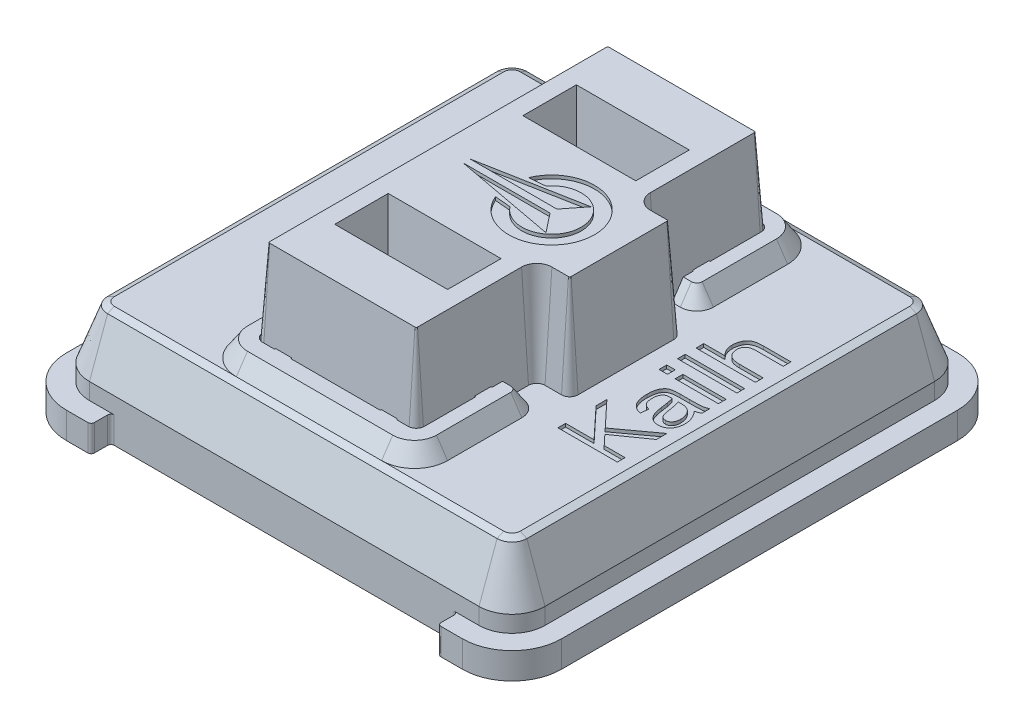
from build123d import *
from OCP.BRepFilletAPI import BRepFilletAPI_MakeChamfer

# Parameters (mm, degrees)
BOSS_EXTRUDE4_DEPTH     = 0.4
BOSS_EXTRUDE5_DEPTH     = 0.5
BOSS_EXTRUDE6_DEPTH     = 1.6
BOSS_EXTRUDE6_TAPER     = 20.000000000000043
CHAMFER1_SIZE           = 0.1
CHAMFER1_SIZE2          = 0.16731571851014881
BOSS_EXTRUDE7_DEPTH     = 0.5
BOSS_EXTRUDE7_TAPER     = 34.000000000000064
CUT_EXTRUDE1_DEPTH      = 11.995908329919814
BOSS_EXTRUDE8_DEPTH     = 0.5
BOSS_EXTRUDE9_DEPTH     = 3
BOSS_EXTRUDE9_DRAFT     = 4.000000000000004
SKETCH13_W              = 1.799999999999999
SKETCH13_H              = 0.23376623376623384
SKETCH13_W_2            = 1.3090909090909086
SKETCH13_H_2            = 0.23376623376623368
SKETCH13_W_3            = 0.25714285714285623
CUT_EXTRUDE2_DEPTH      = 0.1
CUT_EXTRUDE3_DEPTH      = 0.1
BOSS_EXTRUDE10_START    = 1.3
BOSS_EXTRUDE10_DEPTH    = 1.3
BOSS_EXTRUDE11_DEPTH    = 0.9000000000000002
BOSS_EXTRUDE11_TAPER    = 25.000000000000018
CUT_EXTRUDE4_DEPTH      = 4
SKETCH19_R              = 1.6
SKETCH19_R_2            = 0.8999999999999999
BOSS_EXTRUDE12_DEPTH    = 2.65
CHAMFER2_SIZE           = 0.5
SKETCH20_W              = 0.34999999999999964
SKETCH20_H              = 1.15
SKETCH20_W_2            = 0.5
SKETCH20_H_2            = 0.8499999999999996
BOSS_EXTRUDE13_DEPTH    = 3
CUT_EXTRUDE5_REACH      = 18.489
BOSS_EXTRUDE14_START    = 2
BOSS_EXTRUDE14_DEPTH    = 3
MIRROR2_START           = 2
MIRROR2_COPY_1_DEPTH    = 3
CUT_EXTRUDE6_REACH      = 14.137
SKETCH23_W              = 10.5
SKETCH23_H              = 0.599999999999997
FILLET1_R               = 0.1
ESQUISSE1_W             = 16.584048611465096
ESQUISSE1_H             = 15.552754131229735
ENL_V_MAT_EXTRU_1_DEPTH = 10


with BuildPart() as part:
    # Sketch5 → Boss-Extrude4 (new, symmetric)
    with BuildSketch(Plane(origin=(0, 0, 0), x_dir=(1, 0, 0), z_dir=(0, 1, 0))):
        with BuildLine():
            Line((5.999999999999988, -7.4999999999999964), (-5.999999999999988, -7.4999999999999964))
            ThreePointArc((-5.999999999999988, -7.4999999999999964), (-7.06066017177982, -7.060660171779818), (-7.499999999999999, -5.999999999999986))
            Line((-7.499999999999999, -5.999999999999986), (-7.499999999999999, 5.999999999999986))
            ThreePointArc((-7.499999999999999, 5.999999999999986), (-7.06066017177982, 7.060660171779818), (-5.999999999999988, 7.4999999999999964))
            Line((-5.999999999999988, 7.4999999999999964), (5.999999999999988, 7.4999999999999964))
            ThreePointArc((5.999999999999988, 7.4999999999999964), (7.06066017177982, 7.060660171779817), (7.499999999999999, 5.999999999999986))
            Line((7.499999999999999, 5.999999999999986), (7.499999999999999, -5.999999999999986))
            ThreePointArc((7.499999999999999, -5.999999999999986), (7.06066017177982, -7.060660171779817), (5.999999999999988, -7.4999999999999964))
        make_face()
    extrude(amount=BOSS_EXTRUDE4_DEPTH, both=True)

    # Sketch6 → Boss-Extrude5 (add)
    with BuildSketch(Plane(origin=(0, 0.4, 0), x_dir=(1, 0, 0), z_dir=(0, 1, 0))):
        with BuildLine():
            Line((5.899999999999993, -6.900000000000001), (-5.899999999999995, -6.900000000000001))
            ThreePointArc((-5.899999999999995, -6.900000000000001), (-6.607106781186548, -6.607106781186549), (-6.900000000000001, -5.899999999999995))
            Line((-6.900000000000001, -5.899999999999995), (-6.900000000000001, 5.899999999999992))
            ThreePointArc((-6.900000000000001, 5.899999999999992), (-6.607106781186548, 6.6071067811865465), (-5.899999999999995, 6.899999999999999))
            Line((-5.899999999999995, 6.899999999999999), (5.899999999999992, 6.899999999999999))
            ThreePointArc((5.899999999999992, 6.899999999999999), (6.6071067811865465, 6.6071067811865465), (6.899999999999999, 5.899999999999992))
            Line((6.899999999999999, 5.899999999999992), (6.8999999999999995, -5.899999999999995))
            ThreePointArc((6.8999999999999995, -5.899999999999995), (6.607106781186547, -6.607106781186548), (5.899999999999993, -6.900000000000001))
        make_face()
    extrude(amount=BOSS_EXTRUDE5_DEPTH)

    # Sketch7 → Boss-Extrude6 (add)
    with BuildSketch(Plane(origin=(0, 0.9, 0), x_dir=(1, 0, 0), z_dir=(0, 1, 0))):
        with BuildLine():
            Line((-6.900000000000001, 5.899999999999992), (-6.900000000000001, -5.899999999999995))
            ThreePointArc((-6.900000000000001, -5.899999999999995), (-6.607106781186549, -6.607106781186548), (-5.899999999999995, -6.900000000000001))
            Line((-5.899999999999995, -6.900000000000001), (5.899999999999993, -6.900000000000001))
            ThreePointArc((5.899999999999993, -6.900000000000001), (6.607106781186547, -6.607106781186548), (6.8999999999999995, -5.899999999999995))
            Line((6.8999999999999995, -5.899999999999995), (6.899999999999999, 5.899999999999992))
            ThreePointArc((6.899999999999999, 5.899999999999992), (6.6071067811865465, 6.6071067811865465), (5.899999999999992, 6.899999999999999))
            Line((5.899999999999992, 6.899999999999999), (-5.899999999999995, 6.899999999999999))
            ThreePointArc((-5.899999999999995, 6.899999999999999), (-6.607106781186548, 6.6071067811865465), (-6.900000000000001, 5.899999999999992))
        make_face()
    extrude(amount=BOSS_EXTRUDE6_DEPTH, taper=BOSS_EXTRUDE6_TAPER)

    # Chamfer1: one chamfer whose edges measure the first distance from different faces: ONE call of the kernel's chamfer builder (chamfer() names one face for all edges)
    chamfer1_edges_1 = [part.edges().sort_by_distance(p)[0] for p in [
        (-6.195321467907047, 2.5, -6.1953214679070445),
    ]]
    chamfer1_side_1 = [part.faces().sort_by_distance(p)[0] for p in [
        (-6.401214124546798, 1.7000000000000002, -6.4012141245467955),
    ]]
    chamfer1_edges_2 = [part.edges().sort_by_distance(p)[0] for p in [
        (-6.317647625174076, 2.5, 1.38e-15),
    ]]
    chamfer1_side_2 = [part.faces().sort_by_distance(p)[0] for p in [
        (-6.608823812587039, 1.7, 1.04e-15),
    ]]
    chamfer1_edges_3 = [part.edges().sort_by_distance(p)[0] for p in [
        (-6.195321467907047, 2.5, 6.195321467907046),
    ]]
    chamfer1_side_3 = [part.faces().sort_by_distance(p)[0] for p in [
        (-6.401214124546797, 1.7000000000000002, 6.401214124546797),
    ]]
    chamfer1_edges_4 = [part.edges().sort_by_distance(p)[0] for p in [
        (-1.3e-15, 2.5, 6.317647625174076),
    ]]
    chamfer1_side_4 = [part.faces().sort_by_distance(p)[0] for p in [
        (-8.5e-16, 1.7, 6.608823812587039),
    ]]
    chamfer1_edges_5 = [part.edges().sort_by_distance(p)[0] for p in [
        (6.1953214679070445, 2.5, 6.195321467907047),
    ]]
    chamfer1_side_5 = [part.faces().sort_by_distance(p)[0] for p in [
        (6.4012141245467955, 1.7000000000000002, 6.401214124546797),
    ]]
    chamfer1_edges_6 = [part.edges().sort_by_distance(p)[0] for p in [
        (6.317647625174073, 2.5, -3.9e-16),
    ]]
    chamfer1_side_6 = [part.faces().sort_by_distance(p)[0] for p in [
        (6.608823812587037, 1.7000000000000002, 7e-16),
    ]]
    chamfer1_edges_7 = [part.edges().sort_by_distance(p)[0] for p in [
        (6.195321467907045, 2.5, -6.1953214679070445),
    ]]
    chamfer1_side_7 = [part.faces().sort_by_distance(p)[0] for p in [
        (6.4012141245467955, 1.7000000000000002, -6.4012141245467955),
    ]]
    chamfer1_edges_8 = [part.edges().sort_by_distance(p)[0] for p in [
        (-4.1e-16, 2.5, -6.317647625174073),
    ]]
    chamfer1_side_8 = [part.faces().sort_by_distance(p)[0] for p in [
        (-8.5e-16, 1.7, -6.608823812587036),
    ]]
    chamfer1 = BRepFilletAPI_MakeChamfer(part.part.solid().wrapped)
    for e in chamfer1_edges_1:
        chamfer1.Add(CHAMFER1_SIZE, CHAMFER1_SIZE2, e.wrapped, chamfer1_side_1[0].wrapped)  # the first distance lies on this face
    for e in chamfer1_edges_2:
        chamfer1.Add(CHAMFER1_SIZE, CHAMFER1_SIZE2, e.wrapped, chamfer1_side_2[0].wrapped)  # the first distance lies on this face
    for e in chamfer1_edges_3:
        chamfer1.Add(CHAMFER1_SIZE, CHAMFER1_SIZE2, e.wrapped, chamfer1_side_3[0].wrapped)  # the first distance lies on this face
    for e in chamfer1_edges_4:
        chamfer1.Add(CHAMFER1_SIZE, CHAMFER1_SIZE2, e.wrapped, chamfer1_side_4[0].wrapped)  # the first distance lies on this face
    for e in chamfer1_edges_5:
        chamfer1.Add(CHAMFER1_SIZE, CHAMFER1_SIZE2, e.wrapped, chamfer1_side_5[0].wrapped)  # the first distance lies on this face
    for e in chamfer1_edges_6:
        chamfer1.Add(CHAMFER1_SIZE, CHAMFER1_SIZE2, e.wrapped, chamfer1_side_6[0].wrapped)  # the first distance lies on this face
    for e in chamfer1_edges_7:
        chamfer1.Add(CHAMFER1_SIZE, CHAMFER1_SIZE2, e.wrapped, chamfer1_side_7[0].wrapped)  # the first distance lies on this face
    for e in chamfer1_edges_8:
        chamfer1.Add(CHAMFER1_SIZE, CHAMFER1_SIZE2, e.wrapped, chamfer1_side_8[0].wrapped)  # the first distance lies on this face
    add(Compound.cast(chamfer1.Shape()), mode=Mode.REPLACE)

    # Sketch8 → Boss-Extrude7 (add)
    with BuildSketch(Plane(origin=(0, 2.5, 0), x_dir=(1, 0, 0), z_dir=(0, 1, 0))):
        with BuildLine():
            ThreePointArc((2.1999999999999926, -6.150331906663926), (2.907106781186547, -5.857438687850474), (3.1999999999999997, -5.150331906663919))
            Line((3.1999999999999997, -5.150331906663919), (3.1999999999999997, -2.9003319066639257))
            ThreePointArc((3.1999999999999997, -2.9003319066639257), (3.0535533905932737, -2.5467785160706518), (2.6999999999999997, -2.4003319066639257))
            Line((2.6999999999999997, -2.4003319066639257), (2.3000000000000003, -2.4003319066639257))
            Line((2.3000000000000003, -2.4003319066639257), (2.3, 2.4003319066639257))
            Line((2.3, 2.4003319066639257), (2.699999999999996, 2.4003319066639257))
            ThreePointArc((2.699999999999996, 2.4003319066639257), (3.0535533905932737, 2.5467785160706518), (3.1999999999999997, 2.9003319066639293))
            Line((3.1999999999999997, 2.9003319066639293), (3.1999999999999997, 5.150331906663919))
            ThreePointArc((3.1999999999999997, 5.150331906663919), (2.907106781186547, 5.857438687850474), (2.1999999999999926, 6.150331906663926))
            Line((2.1999999999999926, 6.150331906663926), (-2.1999999999999935, 6.150331906663926))
            ThreePointArc((-2.1999999999999935, 6.150331906663926), (-2.907106781186548, 5.857438687850474), (-3.2000000000000006, 5.150331906663919))
            Line((-3.2000000000000006, 5.150331906663919), (-3.2000000000000006, -5.150331906663919))
            ThreePointArc((-3.2000000000000006, -5.150331906663919), (-2.907106781186548, -5.857438687850474), (-2.1999999999999935, -6.150331906663926))
            Line((-2.1999999999999935, -6.150331906663926), (2.1999999999999926, -6.150331906663926))
        make_face()
    extrude(amount=BOSS_EXTRUDE7_DEPTH, taper=BOSS_EXTRUDE7_TAPER)

    # Sketch9 → Cut-Extrude1 (cut, through all)
    with BuildSketch(Plane(origin=(0, 2.5, 0), x_dir=(1, 0, 0), z_dir=(0, 1, 0))):
        with BuildLine():
            Line((-2.1999999999999997, -5.35), (2.2, -5.35))
            ThreePointArc((2.2, -5.35), (2.376776695296637, -5.276776695296636), (2.4500000000000006, -5.1))
            Line((2.4500000000000006, -5.1), (2.4500000000000006, 5.1))
            ThreePointArc((2.4500000000000006, 5.1), (2.376776695296637, 5.276776695296636), (2.2, 5.35))
            Line((2.2, 5.35), (-2.1999999999999997, 5.35))
            ThreePointArc((-2.1999999999999997, 5.35), (-2.3767766952966367, 5.276776695296636), (-2.4499999999999997, 5.1))
            Line((-2.4499999999999997, 5.1), (-2.4499999999999997, -5.1))
            ThreePointArc((-2.4499999999999997, -5.1), (-2.3767766952966367, -5.276776695296636), (-2.1999999999999997, -5.35))
        make_face()
    extrude(amount=CUT_EXTRUDE1_DEPTH, mode=Mode.SUBTRACT)

    # Sketch11 → Boss-Extrude8 (add)
    with BuildSketch(Plane(origin=(0, 2.5, 0), x_dir=(1, 0, 0), z_dir=(0, 1, 0))):
        with BuildLine():
            Line((-1.8598076211353325, 5.35), (-1.3401923788646686, 5.3500000000000005))
            ThreePointArc((-1.3401923788646686, 5.3500000000000005), (-1.6000000000000003, 5.199999999999999), (-1.8598076211353325, 5.35))
        make_face()
        with BuildLine():
            Line((1.3401923788646686, 5.3500000000000005), (1.8598076211353325, 5.35))
            ThreePointArc((1.8598076211353325, 5.35), (1.6000000000000003, 5.199999999999999), (1.3401923788646686, 5.3500000000000005))
        make_face()
        with BuildLine():
            Line((2.4500000000000006, 3.5598076211353322), (2.4500000000000006, 3.040192378864668))
            ThreePointArc((2.4500000000000006, 3.040192378864668), (2.2999999999999994, 3.3), (2.4500000000000006, 3.5598076211353322))
        make_face()
        with BuildLine():
            Line((2.4500000000000006, -3.0401923788646683), (2.4500000000000006, -3.5598076211353313))
            ThreePointArc((2.4500000000000006, -3.5598076211353313), (2.3000000000000007, -3.3), (2.4500000000000006, -3.0401923788646683))
        make_face()
        with BuildLine():
            Line((1.859807621135331, -5.35), (1.3401923788646677, -5.35))
            ThreePointArc((1.3401923788646677, -5.35), (1.6, -5.199999999999998), (1.859807621135331, -5.35))
        make_face()
        with BuildLine():
            Line((-1.3401923788646677, -5.35), (-1.859807621135331, -5.35))
            ThreePointArc((-1.859807621135331, -5.35), (-1.5999999999999992, -5.199999999999999), (-1.3401923788646677, -5.35))
        make_face()
        with BuildLine():
            Line((-2.4499999999999997, -3.5598076211353313), (-2.4499999999999993, -3.0401923788646683))
            ThreePointArc((-2.4499999999999993, -3.0401923788646683), (-2.2999999999999994, -3.3000000000000003), (-2.4499999999999997, -3.5598076211353313))
        make_face()
        with BuildLine():
            Line((-2.449999999999999, 3.0401923788646683), (-2.449999999999999, 3.5598076211353313))
            ThreePointArc((-2.449999999999999, 3.5598076211353313), (-2.299999999999999, 3.3), (-2.449999999999999, 3.0401923788646683))
        make_face()
    extrude(amount=BOSS_EXTRUDE8_DEPTH)


with BuildPart() as boss_extrude9_tool:
    # Sketch12 → Boss-Extrude9 (with draft: the straight prism first)
    with BuildSketch(Plane(origin=(0, 2.5, 0), x_dir=(1, 0, 0), z_dir=(0, 1, 0))):
        with BuildLine():
            ThreePointArc((2.6999999999999993, 1.6999999999999997), (2.5232233047033628, 1.7732233047033628), (2.4499999999999993, 1.9499999999999995))
            Line((2.4499999999999993, 1.9499999999999995), (2.4499999999999997, 5.099999999999998))
            ThreePointArc((2.4499999999999997, 5.099999999999998), (2.3767766952966367, 5.276776695296637), (2.199999999999998, 5.35))
            Line((2.199999999999998, 5.35), (-2.199999999999998, 5.35))
            ThreePointArc((-2.199999999999998, 5.35), (-2.3767766952966367, 5.276776695296637), (-2.4499999999999997, 5.099999999999998))
            Line((-2.4499999999999997, 5.099999999999998), (-2.4499999999999997, -5.099999999999998))
            ThreePointArc((-2.4499999999999997, -5.099999999999998), (-2.3767766952966367, -5.276776695296637), (-2.199999999999998, -5.35))
            Line((-2.199999999999998, -5.35), (2.199999999999998, -5.35))
            ThreePointArc((2.199999999999998, -5.35), (2.3767766952966367, -5.276776695296636), (2.4499999999999997, -5.099999999999998))
            Line((2.4499999999999997, -5.099999999999998), (2.449999999999999, -1.9500000000000004))
            ThreePointArc((2.449999999999999, -1.9500000000000004), (2.5232233047033623, -1.7732233047033634), (2.6999999999999993, -1.7000000000000004))
            Line((2.6999999999999993, -1.7000000000000004), (3.1999999999999975, -1.7000000000000006))
            ThreePointArc((3.1999999999999975, -1.7000000000000006), (3.3767766952966363, -1.6267766952966372), (3.4499999999999993, -1.4499999999999986))
            Line((3.4499999999999993, -1.4499999999999986), (3.4499999999999993, 1.449999999999998))
            ThreePointArc((3.4499999999999993, 1.449999999999998), (3.3767766952966363, 1.6267766952966367), (3.1999999999999975, 1.6999999999999997))
            Line((3.1999999999999975, 1.6999999999999997), (2.6999999999999993, 1.6999999999999997))
        make_face()
        Polygon((-1.5000000000000004, -2.2500000000000013), (1.4999999999999996, -2.2500000000000013), (1.5, -3.4500000000000006), (-1.5, -3.4500000000000006), align=None, mode=Mode.SUBTRACT)
        Polygon((1.4999999999999996, 2.2500000000000013), (1.5, 3.4500000000000006), (-1.5, 3.4500000000000006), (-1.5000000000000004, 2.2500000000000013), align=None, mode=Mode.SUBTRACT)
    extrude(amount=BOSS_EXTRUDE9_DEPTH)
    # Boss-Extrude9: the draft: its side faces are tilted about the plane it starts from
    boss_extrude9_sides = [boss_extrude9_tool.faces().sort_by_distance(p)[0] for p in [
        (2.95, 4, -1.7),
        (2.523223305, 4, -1.773223305),
        (2.45, 4, -3.525),
        (2.376776695, 4, -5.276776695),
        (0, 4, -5.35),
        (-2.376776695, 4, -5.276776695),
        (-2.45, 4, 0),
        (-2.376776695, 4, 5.276776695),
        (0, 4, 5.35),
        (2.376776695, 4, 5.276776695),
        (2.45, 4, 3.525),
        (2.523223305, 4, 1.773223305),
        (2.95, 4, 1.7),
        (3.376776695, 4, 1.626776695),
        (3.45, 4, 0),
        (3.376776695, 4, -1.626776695),
        (0, 4, 2.25),
        (1.5, 4, 2.85),
        (0, 4, 3.45),
        (-1.5, 4, 2.85),
        (0, 4, -2.25),
        (-1.5, 4, -2.85),
        (0, 4, -3.45),
        (1.5, 4, -2.85),
    ]]
    draft(boss_extrude9_sides, Plane(origin=(0, 2.5, 0), x_dir=(1, 0, 0), z_dir=(0, 1, 0)), BOSS_EXTRUDE9_DRAFT)


with BuildPart() as part_1:
    add(part.part)

    # Boss-Extrude9: add boss_extrude9_tool
    add(boss_extrude9_tool.part)

    # Sketch13 → Cut-Extrude2 (cut)
    # profile 1 of 6: a face of its own
    with BuildSketch(Plane(origin=(0, 2.5, 0), x_dir=(1, 0, 0), z_dir=(0, 1, 0))):
        with BuildLine():
            Line((5.808966831260708, 2.641558441558442), (5.808966831260708, 2.407792207792208))
            Line((5.808966831260708, 2.407792207792208), (4.983845078013955, 2.407792207792208))
            add(Edge.make_bspline(
                [(4.983845078013955, 2.407792207792208), (4.970936937987347, 2.407542406260028), (4.945817291259644, 2.4070562846168273), (4.909388829537622, 2.404446327773024), (4.875533983787305, 2.3986845529071656), (4.844041788617271, 2.3916782041743367), (4.815157057405047, 2.3820295974230006), (4.788467982544043, 2.370938235014907), (4.76477812513214, 2.356842463642668), (4.74322837391324, 2.3411870649661166), (4.724636948675216, 2.322986558780508), (4.707844497346048, 2.3033641068930986), (4.694403121572682, 2.2809814749147597), (4.682944049961972, 2.256818630216123), (4.6742465252240155, 2.230417316179967), (4.668184159240792, 2.2019983442445166), (4.66389616835546, 2.1717202021884994), (4.6636423768311674, 2.150786980540251), (4.6635122858061635, 2.1400568181818187)],
                knots=[0, 0, 0, 0, 1.2972783551700766, 2.5245445061948706, 3.6648949627077094, 4.745058113257756, 5.762506365238955, 6.7214970436470525, 7.642596806820658, 8.525874585350033, 9.39109206720355, 10.251017649372987, 11.113376332231878, 12.005421350727158, 12.933884526935351, 13.898554589722258, 14.922819868887679, 16, 16, 16, 16], degree=3))
            add(Edge.make_bspline(
                [(4.6635122858061635, 2.1400568181818187), (4.663785205943969, 2.1292047975292503), (4.664327167446585, 2.107654986414011), (4.66891947185136, 2.0757509701628627), (4.6760240121807595, 2.0445829921752665), (4.686851369518582, 2.014620956025939), (4.700167829324783, 1.9854327210485339), (4.716078390118673, 1.9568415750558832), (4.73570868933388, 1.9296426160727786), (4.7575320886071655, 1.9029132005118794), (4.783330672401592, 1.8782273309201394), (4.814429220574406, 1.8572274976130505), (4.849948580547092, 1.8394512413448831), (4.89005592438308, 1.8249217409321132), (4.934595652434697, 1.8136176473029308), (4.983754863262196, 1.8059125229971111), (5.037541460961735, 1.800531571486795), (5.075023484650014, 1.800181881897381), (5.094518779312656, 1.8000000000000005)],
                knots=[0, 0, 0, 0, 0.8362054097120233, 1.6605265700973175, 2.4801317730402395, 3.2965059310675793, 4.1113678837462215, 4.951934169313966, 5.813922886019306, 6.693615501295894, 7.6099018852787, 8.554965245663075, 9.57498769822485, 10.664785272825679, 11.83718286940016, 13.111757415166943, 14.497756131931636, 16, 16, 16, 16], degree=3))
            Line((5.094518779312656, 1.8000000000000005), (5.808966831260708, 1.8000000000000005))
            Line((5.808966831260708, 1.8000000000000005), (5.808966831260708, 1.5662337662337664))
            Line((5.808966831260708, 1.5662337662337664), (4.008966831260709, 1.5662337662337664))
            Line((4.008966831260709, 1.5662337662337664), (4.008966831260709, 1.8000000000000005))
            Line((4.008966831260709, 1.8000000000000005), (4.654746052039929, 1.8000000000000005))
            add(Edge.make_bspline(
                [(4.654746052039929, 1.8000000000000005), (4.640587268225019, 1.8132416381214425), (4.612790149898402, 1.8392381775496645), (4.576436737364106, 1.8823687896270296), (4.545512997028346, 1.9278700105851003), (4.520153010498332, 1.9758505241977433), (4.500661093710448, 2.026392369279579), (4.486816633622833, 2.079314401328632), (4.478177777445173, 2.1347826772544454), (4.477065304085907, 2.1726549891213955), (4.476499298793176, 2.1919237012987014)],
                knots=[0, 0, 0, 0, 1.0459544956214468, 2.0534617421327868, 3.0380182977429215, 4.011318372678219, 4.9769517403428445, 5.955962446214011, 6.9600325577727205, 8, 8, 8, 8], degree=3))
            add(Edge.make_bspline(
                [(4.476499298793176, 2.1919237012987014), (4.477151582793741, 2.21277888482019), (4.478447675797427, 2.254218284574451), (4.488265102185742, 2.3157097148811725), (4.504316498091638, 2.3757223907282032), (4.523072482923445, 2.424142919941128), (4.5413475287910305, 2.460944025525365), (4.556678390313753, 2.486720067646266), (4.573903343982798, 2.510222970711106), (4.592950461451007, 2.5314273616548295), (4.613634983780957, 2.550582276277968), (4.635796332997107, 2.567919296762635), (4.660269486175782, 2.582453577853053), (4.686358421444562, 2.595400662956551), (4.714781427402648, 2.6063064439066825), (4.745540233069591, 2.6157833065900173), (4.778855645113474, 2.623760719216385), (4.814825745795724, 2.630327347062428), (4.853357065642652, 2.6353283002399457), (4.894542377636706, 2.6389704691017455), (4.938285293293962, 2.641164747420887), (4.968379824838619, 2.64142480221953), (4.983845078013955, 2.641558441558442)],
                knots=[0, 0, 0, 0, 1.5968089331520274, 3.172870842583649, 4.756281426330583, 6.34771723513016, 7.140081275106954, 7.901324872717275, 8.641779931057476, 9.368185131844692, 10.08081263976222, 10.798910289841917, 11.5185804625579, 12.256741901371203, 13.027352034049343, 13.847329809568349, 14.720365742585669, 15.649518335311587, 16.64656909042814, 17.695141442598235, 18.815558199646286, 20, 20, 20, 20], degree=3))
            Line((4.983845078013955, 2.641558441558442), (5.808966831260708, 2.641558441558442))
        make_face()
    # profile 2 of 6: a face of its own
    with BuildSketch(Plane(origin=(0, 2.5, 0), x_dir=(1, 0, 0), z_dir=(0, 1, 0))):
        with Locations((4.908966831260709, 1.1220779220779225)):
            Rectangle(SKETCH13_W, SKETCH13_H)
    # profile 3 of 6: a face of its own
    with BuildSketch(Plane(origin=(0, 2.5, 0), x_dir=(1, 0, 0), z_dir=(0, 1, 0))):
        with Locations((5.154421376715254, 0.5610389610389616)):
            Rectangle(SKETCH13_W_2, SKETCH13_H_2)
    # profile 4 of 6: a face of its own
    with BuildSketch(Plane(origin=(0, 2.5, 0), x_dir=(1, 0, 0), z_dir=(0, 1, 0))):
        with Locations((4.137538259832137, 0.5610389610389616)):
            Rectangle(SKETCH13_W_3, SKETCH13_H_2)
    # profile 5 of 6: a face of its own
    with BuildSketch(Plane(origin=(0, 2.5, 0), x_dir=(1, 0, 0), z_dir=(0, 1, 0))):
        with BuildLine():
            Line((5.808966831260708, 0.18701298701298769), (5.808966831260708, -0.04675324675324595))
            add(Edge.make_bspline(
                [(5.808966831260708, -0.04675324675324595), (5.7976142124163745, -0.05478679368631185), (5.7743238351672606, -0.07126795466644732), (5.733813191132734, -0.08980997433740275), (5.689119615174492, -0.10624044539384754), (5.656887568182907, -0.11325507851090857), (5.640216831260709, -0.11688311688311617)],
                knots=[0, 0, 0, 0, 0.903907977573099, 1.8544054094329567, 2.8902770286238817, 4, 4, 4, 4], degree=3))
            add(Edge.make_bspline(
                [(5.640216831260709, -0.11688311688311617), (5.655516269991555, -0.13501758155964783), (5.685611532777377, -0.17068957512239877), (5.724423214156069, -0.22753996575106764), (5.758209315632795, -0.2850162411995688), (5.785193746113217, -0.3439309765148028), (5.806296030921507, -0.40396525614362766), (5.821118572850905, -0.4650232117771859), (5.830806032465317, -0.5272477785338032), (5.83182865628761, -0.5691604908149904), (5.832343454637331, -0.5902597402597396)],
                knots=[0, 0, 0, 0, 1.0892239949737048, 2.142593786481002, 3.1574900276556006, 4.148481358184637, 5.114232063249363, 6.075958248606488, 7.031419475255834, 8, 8, 8, 8], degree=3))
            add(Edge.make_bspline(
                [(5.832343454637331, -0.5902597402597396), (5.832153360297348, -0.6068352336235396), (5.831783364459901, -0.6390974437912494), (5.826299867785243, -0.6860584678131948), (5.818566199820707, -0.7303404833298883), (5.807164390100491, -0.7719074962510519), (5.792565368740574, -0.8108311868327565), (5.774591503740437, -0.8471820687217165), (5.753427790168004, -0.8809496085632283), (5.728914091941531, -0.9115819072067921), (5.701926449075696, -0.9389415065317661), (5.672743481759093, -0.9630412796162902), (5.641437274499284, -0.9835012763922452), (5.607803212122262, -1.0000777379656591), (5.572247331081473, -1.012844349874836), (5.534551659180995, -1.0220298965542784), (5.49476474669227, -1.027559476424988), (5.46746671619991, -1.0282300400753384), (5.453569103987981, -1.028571428571428)],
                knots=[0, 0, 0, 0, 1.2168275773517123, 2.368408962361388, 3.4683010163723482, 4.516243969315997, 5.529495403481963, 6.5174065446954765, 7.490059769080957, 8.451006561644878, 9.39329404916929, 10.30823430893489, 11.226054902901527, 12.133974608059562, 13.056228933753905, 13.995455658021518, 14.979472898814782, 16, 16, 16, 16], degree=3))
            add(Edge.make_bspline(
                [(5.453569103987981, -1.028571428571428), (5.440276716431007, -1.0282386520238744), (5.414063323195936, -1.0275823965195083), (5.375806254773276, -1.021871116649069), (5.3390927196081, -1.0132772402654373), (5.304512495067037, -1.0003745013096057), (5.271566778477137, -0.9841331764233306), (5.240409017381131, -0.9643582816606489), (5.211090288328932, -0.9407738117304028), (5.1833836727754115, -0.9136089664633258), (5.15795231534794, -0.8817760352618369), (5.13488061401357, -0.844866649676713), (5.114139733934651, -0.8025902440879535), (5.095679414069346, -0.754997155547491), (5.079325113390285, -0.7022504346619654), (5.065164097593691, -0.6443006182713761), (5.053127451273279, -0.5811412956759465), (5.047187307794613, -0.5370866020377416), (5.044112935156812, -0.5142857142857136)],
                knots=[0, 0, 0, 0, 0.8723930238073564, 1.7204118741329395, 2.5348632349864415, 3.3443153788029036, 4.138098067301036, 4.94323479147576, 5.762342769512937, 6.604727131961653, 7.486268004825613, 8.431224693875162, 9.457417050898199, 10.573914373813508, 11.780129899965775, 13.081285495030452, 14.489394061968598, 16, 16, 16, 16], degree=3))
            Line((5.044112935156812, -0.5142857142857136), (5.013065857234734, -0.3075487012987006))
            add(Edge.make_bspline(
                [(5.013065857234734, -0.3075487012987006), (5.009896710319499, -0.2890201951662468), (5.003852868143418, -0.2536847027393368), (4.993323302570418, -0.2032936700516332), (4.98157734400181, -0.15810403775962822), (4.971952893840244, -0.13010418045169944), (4.967408389702267, -0.11688311688311617)],
                knots=[0, 0, 0, 0, 1.1488224325496723, 2.190905520122856, 3.145775892462998, 4, 4, 4, 4], degree=3))
            add(Edge.make_bspline(
                [(4.967408389702267, -0.11688311688311617), (4.95304107021996, -0.11694396018433391), (4.926493015823697, -0.11705638695067444), (4.890070365263306, -0.11806677840113408), (4.8604658690387765, -0.11983126638462667), (4.8364582839742125, -0.12214155383125126), (4.81566680551623, -0.12674692451881112), (4.795757381699826, -0.13432927622266846), (4.775374880962566, -0.14450518928822909), (4.754952336348308, -0.15769797821147805), (4.734703780341986, -0.17395791515244927), (4.7174165483276935, -0.1957166318549965), (4.70150768066083, -0.22127282907797702), (4.6875739870774344, -0.2513427888570909), (4.676773198610864, -0.28648013751264984), (4.668775091981783, -0.32672078121836107), (4.664166633552748, -0.3724577255824632), (4.6637381327209235, -0.40481871911371503), (4.6635122858061635, -0.4218749999999993)],
                knots=[0, 0, 0, 0, 1.35198280768947, 2.4982052612913668, 3.427994317730636, 4.142845712581893, 4.765440227987405, 5.4251923990055335, 6.1425184454865365, 6.905253036974828, 7.710596233249315, 8.573154591471647, 9.504636226477706, 10.54009170818831, 11.681494222231183, 12.955497740723338, 14.395355641877869, 16, 16, 16, 16], degree=3))
            add(Edge.make_bspline(
                [(4.6635122858061635, -0.4218749999999993), (4.66393136843903, -0.4435889493922598), (4.664727068565052, -0.4848165997715033), (4.674441945468665, -0.5430927387032761), (4.689451627101745, -0.5943968270216485), (4.7074865821939555, -0.63235510297392), (4.726433230928832, -0.6582766817166884), (4.743016668396578, -0.6759110272748095), (4.762183690184085, -0.6920033701799613), (4.783843221089238, -0.7068062978877482), (4.808520052437821, -0.7194073324106408), (4.8356450202931605, -0.7306943483333374), (4.865364001637794, -0.7407541968167183), (4.886391065493827, -0.7455623622273017), (4.897278519572397, -0.7480519480519473)],
                knots=[0, 0, 0, 0, 1.7542902106465328, 3.330820301812233, 4.7604713821246065, 6.0681986003606685, 6.702305717905518, 7.350099905606375, 8.020759658183286, 8.72256691010055, 9.46680753417905, 10.256730987815589, 11.097365117322028, 12, 12, 12, 12], degree=3))
            Line((4.897278519572397, -0.7480519480519473), (4.869518779312656, -0.9818181818181811))
            add(Edge.make_bspline(
                [(4.869518779312656, -0.9818181818181811), (4.853611193018221, -0.9786017816846534), (4.822520424961833, -0.9723154508311147), (4.7779582503051286, -0.9577116763605429), (4.736375461913592, -0.9401017094407711), (4.698028692803322, -0.9184783635958045), (4.662206250314258, -0.8942256914916684), (4.630102405191615, -0.8653595010460773), (4.60073240624794, -0.8334501386405557), (4.574196642027063, -0.7982237274884666), (4.551183080742637, -0.7591558796600055), (4.531227592657335, -0.7166636573486271), (4.513752885558066, -0.6708727288596874), (4.500747320962618, -0.6212823703099524), (4.489461909514712, -0.5685697104505628), (4.48216824521634, -0.5122547146028833), (4.477156426962759, -0.45252638307886056), (4.476722437161997, -0.4115373902981895), (4.476499298793176, -0.39046266233766164)],
                knots=[0, 0, 0, 0, 0.9951774450735463, 1.9450361951236252, 2.8721424933872783, 3.7618547880388564, 4.642675727118209, 5.5212756524060795, 6.404343627695985, 7.300931216189511, 8.222238890582595, 9.181425829138911, 10.179208271910753, 11.225067007971875, 12.32407275364409, 13.485342137314333, 14.707074100271779, 15.999999999999998, 15.999999999999998, 15.999999999999998, 15.999999999999998], degree=3))
            add(Edge.make_bspline(
                [(4.476499298793176, -0.39046266233766164), (4.476690890893722, -0.37146355115084456), (4.477060875118252, -0.3347742962221728), (4.480416422626953, -0.28163635012060095), (4.485659187798085, -0.23246808108091682), (4.493498525945788, -0.18727794431895398), (4.5026469171851735, -0.1457532426678561), (4.514752157830967, -0.10832524552016949), (4.528482033470439, -0.07448630485279219), (4.545116255570697, -0.04485864995814117), (4.563264378078302, -0.01855796061888742), (4.581670847281791, 0.00547334865447952), (4.601749896386381, 0.02621628443629191), (4.621820185599408, 0.04508781077848085), (4.643537404904793, 0.0604805419614025), (4.665690642724296, 0.0738796146888784), (4.689228602685101, 0.08404616835430385), (4.722566345759465, 0.0943999283171139), (4.768238755204122, 0.10365778184610963), (4.828163487433543, 0.1115379776553433), (4.895134857767431, 0.11622508593443337), (4.9420761195692435, 0.11665683743575028), (4.966677870221747, 0.11688311688311769)],
                knots=[0, 0, 0, 0, 1.3680119790864425, 2.6417730678372706, 3.8326947334090917, 4.926724950007907, 5.9433607856030335, 6.891650018276866, 7.756279054183268, 8.5686987674416, 9.332293288262912, 10.056676126852098, 10.745093071296735, 11.409183828571438, 12.03703833990536, 12.658060448387348, 13.270544693548068, 13.877797974739176, 15.169269560119256, 16.620050137650292, 18.228580133133942, 20, 20, 20, 20], degree=3))
            Line((4.966677870221747, 0.11688311688311769), (5.263634039052916, 0.11688311688311769))
            add(Edge.make_bspline(
                [(5.263634039052916, 0.11688311688311769), (5.285306604219437, 0.11680766704013286), (5.326826888673487, 0.11666312028626807), (5.386239281380564, 0.11764517754584121), (5.4401808290261755, 0.1182072909926659), (5.488518290325094, 0.11932409986274001), (5.531263560697876, 0.1206639341543883), (5.5683832596522675, 0.12268531406128662), (5.5999640343828165, 0.1241621792101879), (5.634654478790087, 0.12759156067832103), (5.674206196801377, 0.13402894690695613), (5.720028491512467, 0.14648759100218836), (5.7652765300564655, 0.16413567534602305), (5.7942463337230565, 0.17930497400370782), (5.808966831260708, 0.18701298701298769)],
                knots=[0, 0, 0, 0, 1.4020777770497348, 2.686099577161881, 3.844102432396371, 4.891988820243759, 5.814117699366312, 6.610652945285454, 7.297068948043889, 7.85903618239089, 8.865208258249554, 9.885586107423354, 10.925597672063347, 12, 12, 12, 12], degree=3))
        make_face()
        with BuildLine():
            Line((5.231491181910059, -0.11688311688311617), (5.154421376715254, -0.11688311688311617))
            add(Edge.make_bspline(
                [(5.154421376715254, -0.11688311688311617), (5.163538374613043, -0.14747267198052594), (5.182578995621711, -0.21135818911712592), (5.205221559389253, -0.3133502532226805), (5.226635689822146, -0.4247120728618546), (5.239058906237353, -0.5224414562363454), (5.251092974071679, -0.6000560066001811), (5.265639576753102, -0.6516246800568167), (5.284349500018401, -0.6956652159816192), (5.307786476295021, -0.7319925996799516), (5.3361540028935375, -0.7602818361734104), (5.368992798805446, -0.780499346457833), (5.406475469569275, -0.7926975490106483), (5.432899105806853, -0.7940845112753719), (5.446629168923046, -0.7948051948051941)],
                knots=[0, 0, 0, 0, 1.446121225911983, 3.020187840764769, 4.732247023019203, 6.583196502551875, 7.484893360313893, 8.288294041376107, 9.004862087602321, 9.6460887311044, 10.235252101471714, 10.804947704369333, 11.379035372019407, 12, 12, 12, 12], degree=3))
            add(Edge.make_bspline(
                [(5.446629168923046, -0.7948051948051941), (5.460491689532467, -0.7939842827205499), (5.4876249278722895, -0.7923775039913225), (5.526238858135616, -0.7790305654380151), (5.560657043945748, -0.7571054328140445), (5.590913501868879, -0.727149957006497), (5.61552960733233, -0.6888099645478853), (5.63340786038711, -0.6429337775462531), (5.64334186146863, -0.5895830167494668), (5.644641620612083, -0.5518277417010625), (5.645330467624344, -0.5318181818181812)],
                knots=[0, 0, 0, 0, 0.8977169149362771, 1.7571095258176086, 2.616284247168069, 3.5268401459519625, 4.4975412941161785, 5.550848533269103, 6.701997459349198, 8, 8, 8, 8], degree=3))
            add(Edge.make_bspline(
                [(5.645330467624344, -0.5318181818181812), (5.645059816486738, -0.5182914366917553), (5.644526802104939, -0.4916521631417747), (5.639999444320767, -0.45232488130619447), (5.632693989435125, -0.41422847170043825), (5.622564955468927, -0.377116921177217), (5.608861803026345, -0.3414687079039025), (5.592867724541663, -0.3067108371607533), (5.5732979775351685, -0.2737084251734532), (5.551687240313811, -0.24163249919229488), (5.52610708733106, -0.2122395124236023), (5.49624667626021, -0.18632947228497648), (5.461999306362794, -0.1648604753962989), (5.423805879579481, -0.14718964027836165), (5.381535440461846, -0.13329842918051105), (5.335095634428324, -0.12370284527253757), (5.284610176179945, -0.11772783982109081), (5.249650332373793, -0.11717189213463755), (5.231491181910059, -0.11688311688311617)],
                knots=[0, 0, 0, 0, 0.9742687295202695, 1.9187033506071718, 2.847654724651387, 3.766990184658006, 4.685823367012852, 5.596202204231952, 6.519920943638875, 7.44692391584235, 8.379347399321487, 9.318389875563016, 10.28445050102422, 11.281203512920856, 12.343569689907493, 13.482447171285905, 14.692310501428114, 16, 16, 16, 16], degree=3))
        make_face(mode=Mode.SUBTRACT)
    # profile 6 of 6: a face of its own
    with BuildSketch(Plane(origin=(0, 2.5, 0), x_dir=(1, 0, 0), z_dir=(0, 1, 0))):
        Polygon((5.808966831260708, -1.1162337662337647), (5.808966831260708, -1.4318181818181803), (4.89253014294902, -2.0794237012987), (5.177798000091877, -2.3844155844155828), (5.808966831260708, -2.3844155844155828), (5.808966831260708, -2.618181818181817), (4.008966831260709, -2.618181818181817), (4.008966831260709, -2.3844155844155828), (4.870249298793176, -2.3844155844155828), (4.008966831260709, -1.4628652597402583), (4.008966831260709, -1.1337662337662322), (4.731085337754215, -1.9062905844155829), align=None)
    extrude(amount=-CUT_EXTRUDE2_DEPTH, mode=Mode.SUBTRACT)

    # Sketch14 → Cut-Extrude3 (cut)
    with BuildSketch(Plane(origin=(0, 5.5, 0), x_dir=(1, 0, 0), z_dir=(0, 1, 0))):
        with BuildLine():
            Line((-6e-17, 0.5), (0.48160627441798054, 0.542135089294529))
            ThreePointArc((0.48160627441798054, 0.542135089294529), (2.1, 0), (0.48160627441798065, -0.5421350892945288))
            Line((0.48160627441798065, -0.5421350892945288), (6e-17, -0.5))
            ThreePointArc((6e-17, -0.5), (2.5, 0), (-6e-17, 0.5))
        make_face()
        Polygon((-1.3770266337362267, 0.10429765388477082), (1.2555931951855341, 0.10429765388477082), (1.7122269842043876, 0.6819198827291325), align=None)
        Polygon((1.2555931951855333, -0.10429765388477082), (1.7122269842043867, -0.6819198827291325), (-1.3770266337362258, -0.10429765388477082), align=None)
    extrude(amount=-CUT_EXTRUDE3_DEPTH, mode=Mode.SUBTRACT)

    # Sketch16 → Boss-Extrude10 (add)
    with BuildSketch(Plane.XZ.offset(0.4).offset(BOSS_EXTRUDE10_START)):
        with BuildLine():
            Line((5.900000000000002, -6.900000000000002), (-5.899999999999999, -6.900000000000004))
            ThreePointArc((-5.899999999999999, -6.900000000000004), (-6.6071067811865465, -6.607106781186552), (-6.899999999999999, -5.900000000000004))
            Line((-6.899999999999999, -5.900000000000004), (-6.899999999999999, 5.8999999999999915))
            ThreePointArc((-6.899999999999999, 5.8999999999999915), (-6.6071067811865465, 6.607106781186545), (-5.899999999999992, 6.899999999999999))
            Line((-5.899999999999992, 6.899999999999999), (5.900000000000002, 6.8999999999999995))
            ThreePointArc((5.900000000000002, 6.8999999999999995), (6.60710678118655, 6.6071067811865465), (6.900000000000002, 5.8999999999999995))
            Line((6.900000000000002, 5.8999999999999995), (6.900000000000002, -5.900000000000002))
            ThreePointArc((6.900000000000002, -5.900000000000002), (6.60710678118655, -6.60710678118655), (5.900000000000002, -6.900000000000002))
        make_face()
    extrude(amount=-BOSS_EXTRUDE10_DEPTH)

    # Sketch17 → Boss-Extrude11 (add)
    with BuildSketch(Plane.XZ.offset(1.7)):
        with BuildLine():
            Line((-5.899999999999999, -6.900000000000004), (5.900000000000002, -6.900000000000002))
            ThreePointArc((5.900000000000002, -6.900000000000002), (6.60710678118655, -6.60710678118655), (6.900000000000002, -5.900000000000002))
            Line((6.900000000000002, -5.900000000000002), (6.900000000000002, 5.8999999999999995))
            ThreePointArc((6.900000000000002, 5.8999999999999995), (6.60710678118655, 6.6071067811865465), (5.900000000000002, 6.8999999999999995))
            Line((5.900000000000002, 6.8999999999999995), (-5.899999999999992, 6.899999999999999))
            ThreePointArc((-5.899999999999992, 6.899999999999999), (-6.6071067811865465, 6.607106781186546), (-6.899999999999999, 5.8999999999999915))
            Line((-6.899999999999999, 5.8999999999999915), (-6.899999999999999, -5.900000000000004))
            ThreePointArc((-6.899999999999999, -5.900000000000004), (-6.6071067811865465, -6.607106781186552), (-5.899999999999999, -6.900000000000004))
        make_face()
    extrude(amount=BOSS_EXTRUDE11_DEPTH, taper=BOSS_EXTRUDE11_TAPER)

    # Sketch18 → Cut-Extrude4 (cut)
    with BuildSketch(Plane.XZ.offset(2.6)):
        Polygon((-6.275, 2.5000000000000013), (-3.125, 2.5000000000000013), (-3.1249999999999996, -2.4999999999999987), (-6.2749999999999995, -2.4999999999999987), align=None)
    extrude(amount=-CUT_EXTRUDE4_DEPTH, mode=Mode.SUBTRACT)

    # Sketch19 → Boss-Extrude12 (add)
    with BuildSketch(Plane.XZ.offset(2.6)):
        with Locations(Location((0, 0, 0), (0, 0, 270))):
            Circle(SKETCH19_R)
        with Locations(Location((0, 5.5, 0), (0, 0, 270))):
            Circle(SKETCH19_R_2)
        with Locations(Location((0, -5.5, 0), (0, 0, 90))):
            Circle(SKETCH19_R_2)
    extrude(amount=BOSS_EXTRUDE12_DEPTH)

    # Chamfer2
    chamfer2_edges = [part_1.edges().sort_by_distance(p)[0] for p in [
        (4.9e-16, -5.25, 1.6),
        (2.8e-16, -5.25, 6.4),
        (-1.7e-16, -5.25, -6.4),
    ]]
    chamfer(chamfer2_edges, length=CHAMFER2_SIZE)

    # Sketch20 → Boss-Extrude13 (add)
    with BuildSketch(Plane.XZ.offset(2.6)):
        with Locations((5.9, 0)):
            Rectangle(SKETCH20_W, SKETCH20_H)
        with Locations((3.8, 5)):
            Rectangle(SKETCH20_W_2, SKETCH20_H_2)
    extrude(amount=BOSS_EXTRUDE13_DEPTH)

    # Cut-Extrude5: up to this face of the body (flat: up to its plane)
    cut_extrude5_end = Plane(part_1.part.faces().sort_by_distance((3.55, -4.1, 5))[0])
    # Sketch21 → Cut-Extrude5 (cut, up to the picked face)
    with BuildSketch(Plane(origin=(6.075, 0, 0), x_dir=(0, 0, -1), z_dir=(1, 0, 0)), mode=Mode.PRIVATE) as cut_extrude5_sk1:
        with BuildLine():
            Line((-0.575, -4.854070785647887), (-0.21650635094611032, -5.474999999999998))
            ThreePointArc((-0.21650635094611032, -5.474999999999998), (-1e-16, -5.6), (0.21650635094610995, -5.474999999999998))
            Line((0.21650635094610995, -5.474999999999998), (0.575, -4.854070785647887))
            Line((0.575, -4.854070785647887), (0.575, -6.700000000000001))
            Line((0.575, -6.700000000000001), (-5.425, -6.700000000000001))
            Line((-5.425, -6.700000000000001), (-5.425, -5.278553390593273))
            Line((-5.425, -5.278553390593273), (-5.17677669529664, -5.526776695296638))
            ThreePointArc((-5.17677669529664, -5.526776695296638), (-5.000000000000001, -5.600000000000002), (-4.823223304703363, -5.526776695296636))
            Line((-4.823223304703363, -5.526776695296636), (-4.575, -5.278553390593272))
            Line((-4.575, -5.278553390593272), (-4.575, -5.7))
            Line((-4.575, -5.7), (-0.5749999999999998, -5.7))
            Line((-0.5749999999999998, -5.7), (-0.575, -4.854070785647887))
        make_face()
    cut_extrude5_tool1 = split(extrude(cut_extrude5_sk1.sketch, amount=-CUT_EXTRUDE5_REACH, mode=Mode.PRIVATE), bisect_by=cut_extrude5_end, keep=Keep.BOTH, mode=Mode.PRIVATE)
    add(cut_extrude5_tool1.solids().sort_by(Axis((6.075, -6.130426, 2.337222), (-1, 0, 0)))[0], mode=Mode.SUBTRACT)

    # Sketch22 → Boss-Extrude14 (add)
    with BuildSketch(Plane(origin=(0, 0, 0), x_dir=(0, 0, -1), z_dir=(1, 0, 0)).offset(BOSS_EXTRUDE14_START)):
        Polygon((-6.8999999999999995, -1.7), (-7.25, -1.7), (-7.25, -1.95), (-6.611533244723425, -2.3186189530275523), align=None)
    boss_extrude14 = extrude(amount=BOSS_EXTRUDE14_DEPTH)

    # Mirror1: Boss-Extrude14 across plane
    add(boss_extrude14.mirror(Plane(origin=(0, 0, 0), x_dir=(0, 0, 1), z_dir=(1, 0, 0))))

    # Mirror2: Boss-Extrude14 across plane
    add(boss_extrude14.mirror(Plane.XY))

    # Mirror2 copy 1 sketch → Mirror2 copy 1 (add)
    with BuildSketch(Plane.ZY.offset(MIRROR2_START)):
        Polygon((-6.8999999999999995, -1.7), (-7.25, -1.7), (-7.25, -1.95), (-6.611533244723425, -2.3186189530275523), align=None)
    extrude(amount=MIRROR2_COPY_1_DEPTH)

    # Sketch23 → Cut-Extrude6 (cut, up to next)
    with BuildSketch(Plane.XZ.offset(0.4), mode=Mode.PRIVATE) as cut_extrude6_sk1:
        with Locations((0, 7.1999999999999975)):
            Rectangle(SKETCH23_W, SKETCH23_H)
    cut_extrude6_tool1 = extrude(cut_extrude6_sk1.sketch, amount=-CUT_EXTRUDE6_REACH, mode=Mode.PRIVATE) & part_1.part
    # Sketch23 → Cut-Extrude6 (cut, up to next)
    with BuildSketch(Plane.XZ.offset(0.4), mode=Mode.PRIVATE) as cut_extrude6_sk2:
        with Locations((0, -7.1999999999999975)):
            Rectangle(SKETCH23_W, SKETCH23_H)
    cut_extrude6_tool2 = extrude(cut_extrude6_sk2.sketch, amount=-CUT_EXTRUDE6_REACH, mode=Mode.PRIVATE) & part_1.part
    add(cut_extrude6_tool1.solids().sort_by_distance((0, -0.4, 7.2))[0], mode=Mode.SUBTRACT)
    add(cut_extrude6_tool2.solids().sort_by_distance((0, -0.4, -7.2))[0], mode=Mode.SUBTRACT)

    # Fillet1
    fillet1_edges = [part_1.edges().sort_by_distance(p)[0] for p in [
        (-5.25, 0, 6.8999999999999995),
        (-5.25, 0, 7.4999999999999964),
        (5.25, 0, 7.4999999999999964),
        (5.25, 0, 6.8999999999999995),
        (5.25, 0, -7.4999999999999964),
        (-5.25, 0, -7.4999999999999964),
        (-5.25, 0, -6.8999999999999995),
        (5.25, 0, -6.8999999999999995),
    ]]
    fillet(fillet1_edges, radius=FILLET1_R)

    # Esquisse1 → Enlèv. mat.-Extru.1 (cut)
    with BuildSketch(Plane.XZ.offset(0.4)):
        with Locations((0.05208557980988004, 0.19271664529654586)):
            Rectangle(ESQUISSE1_W, ESQUISSE1_H)
    extrude(amount=ENL_V_MAT_EXTRU_1_DEPTH, mode=Mode.SUBTRACT)


solid = part_1.part
